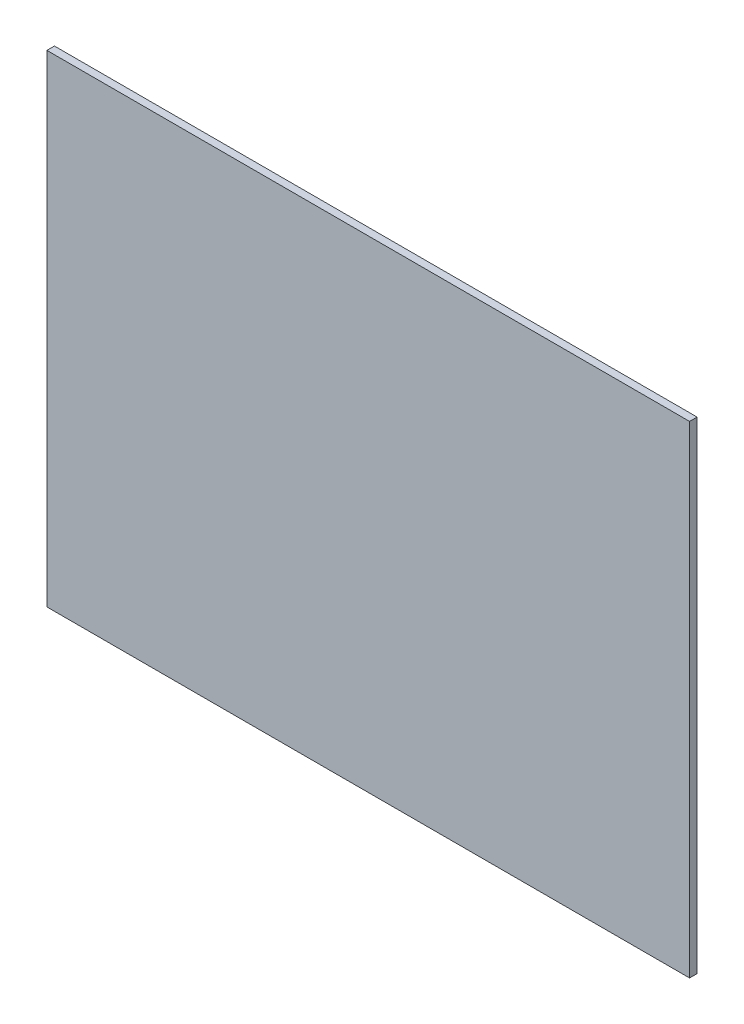
from build123d import *

# Parameters (mm, degrees)
SKETCH1_W           = 406.4
SKETCH1_H           = 304.8
BOSS_EXTRUDE1_DEPTH = 4.7625


with BuildPart() as part:
    # Sketch1 → Boss-Extrude1 (new body)
    with BuildSketch(Plane.XY):
        with Locations((203.2, 152.4)):
            Rectangle(SKETCH1_W, SKETCH1_H)
    extrude(amount=BOSS_EXTRUDE1_DEPTH)


solid = part.part
